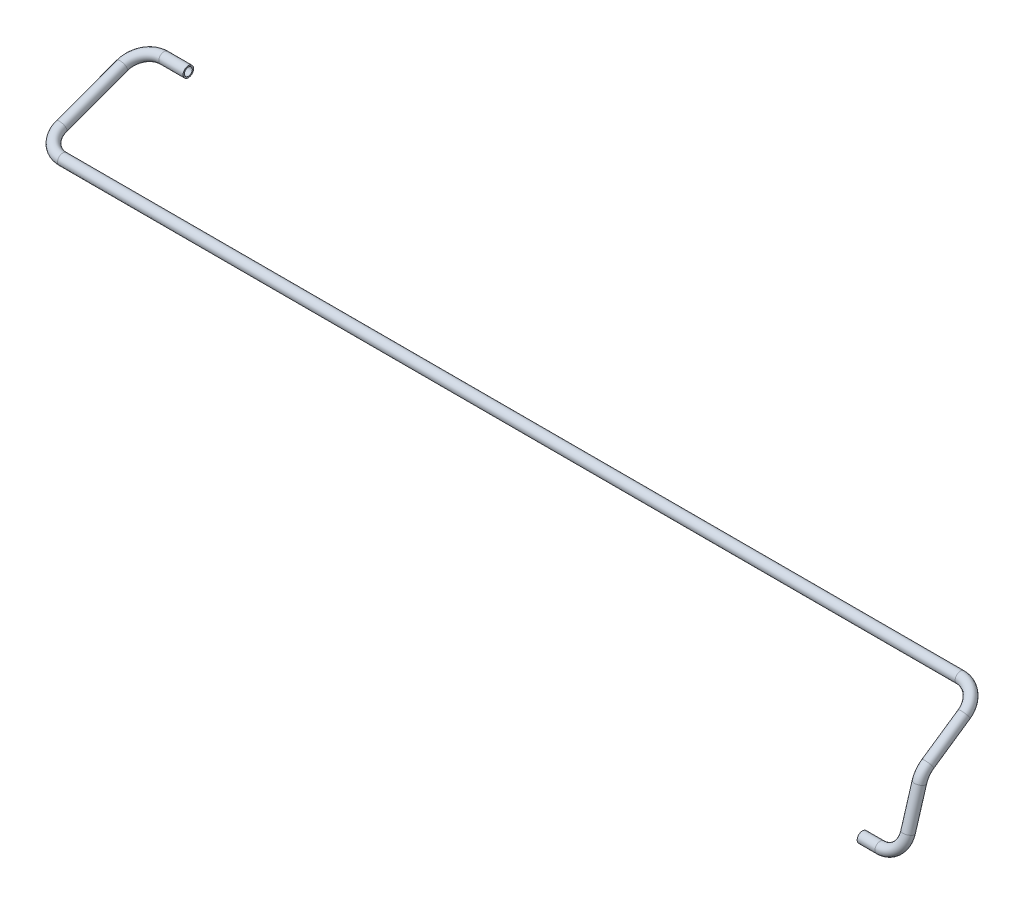
from build123d import *

# Parameters (mm, degrees)
SKETCH1_R   = 8
SKETCH1_R_2 = 6


with BuildPart() as part:
    # Sweep1: sweep along a curve in space
    with BuildLine() as sweep1_path:
        Line((0, 0, 0), (27, 0, 0))
        ThreePointArc((27, 0, 0), (50.334523779, 9.257847184, -2.777354155), (60, 31.608267412, -9.482480224))
        Line((60, 31.608267412, -9.482480224), (60, 88.838550515, -26.651565155))
        ThreePointArc((60, 106.583948568, -39.614655052), (60, 98.822015689, -31.612563105), (60, 88.838550515, -26.651565155))
        Line((60, 106.583948568, -39.614655052), (60, 144.354822485, -94.772121724))
        ThreePointArc((27, 163, -122), (50.334523779, 157.538953942, -114.02513909), (60, 144.354822485, -94.772121724))
        Line((27, 163, -122), (-1338.5, 163, -122))
        ThreePointArc((-1338.5, 163, -122), (-1361.834523779, 166.32911638, -131.074051725), (-1371.5, 174.366314294, -152.980750465))
        Line((-1371.5, 174.366314294, -152.980750465), (-1371.5, 208.133685706, -245.019249535))
        ThreePointArc((-1338.5, 219.5, -276), (-1361.834523779, 216.17088362, -266.925948275), (-1371.5, 208.133685706, -245.019249535))
        Line((-1338.5, 219.5, -276), (-1301.5, 219.5, -276))
    # Sketch1 → Sweep1 (sweep)
    with BuildSketch(Plane(origin=(0, 0, 0), x_dir=(0, 0, -1), z_dir=(1, 0, 0))):
        Circle(SKETCH1_R)
        Circle(SKETCH1_R_2, mode=Mode.SUBTRACT)
    sweep(path=sweep1_path.line)


solid = part.part
